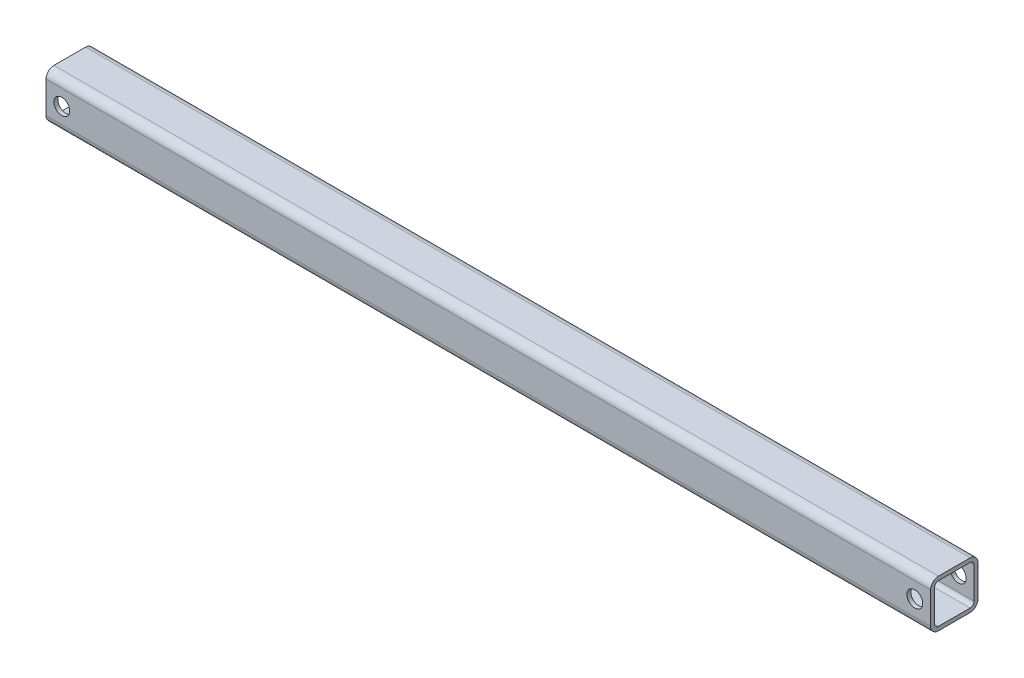
from build123d import *

# Parameters (mm, degrees)
STRUCTURAL_MEMBER1_DEPTH = 711.2
SKETCH2_R                = 6.35
CUT_EXTRUDE1_DEPTH       = 713.474527615
SKETCH3_R                = 6.35
CUT_EXTRUDE2_DEPTH       = 713.474527615


with BuildPart() as part:
    # Sketch1 → Structural Member1 (new body)
    with BuildSketch(Plane(origin=(0, 0, 0), x_dir=(0, 0, -1), z_dir=(1, 0, 0))):
        with BuildLine():
            Line((-12.7, -19.05), (12.7, -19.05))
            ThreePointArc((12.7, -19.05), (17.190128061, -17.190128061), (19.05, -12.7))
            Line((19.05, -12.7), (19.05, 12.7))
            ThreePointArc((19.05, 12.7), (17.190128061, 17.190128061), (12.7, 19.05))
            Line((12.7, 19.05), (-12.7, 19.05))
            ThreePointArc((-12.7, 19.05), (-17.190128061, 17.190128061), (-19.05, 12.7))
            Line((-19.05, 12.7), (-19.05, -12.7))
            ThreePointArc((-19.05, -12.7), (-17.190128061, -17.190128061), (-12.7, -19.05))
        make_face()
        with BuildLine():
            Line((-12.7, -15.875), (12.7, -15.875))
            ThreePointArc((12.7, -15.875), (14.94506403, -14.94506403), (15.875, -12.7))
            Line((15.875, -12.7), (15.875, 12.7))
            ThreePointArc((15.875, 12.7), (14.94506403, 14.94506403), (12.7, 15.875))
            Line((12.7, 15.875), (-12.7, 15.875))
            ThreePointArc((-12.7, 15.875), (-14.94506403, 14.94506403), (-15.875, 12.7))
            Line((-15.875, 12.7), (-15.875, -12.7))
            ThreePointArc((-15.875, -12.7), (-14.94506403, -14.94506403), (-12.7, -15.875))
        make_face(mode=Mode.SUBTRACT)
    extrude(amount=STRUCTURAL_MEMBER1_DEPTH)

    # Sketch2 → Cut-Extrude1 (cut, through all)
    with BuildSketch(Plane.XY.offset(19.05)):
        with Locations((12.7, 0)):
            Circle(SKETCH2_R)
    extrude(amount=-CUT_EXTRUDE1_DEPTH, mode=Mode.SUBTRACT)

    # Sketch3 → Cut-Extrude2 (cut, through all)
    with BuildSketch(Plane.XY.offset(19.05)):
        with Locations((698.5, 0)):
            Circle(SKETCH3_R)
    extrude(amount=-CUT_EXTRUDE2_DEPTH, mode=Mode.SUBTRACT)


solid = part.part
